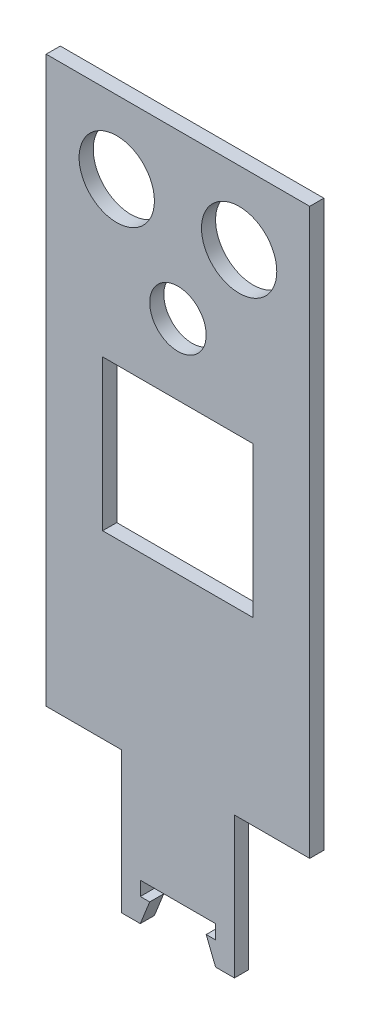
from build123d import *

# Parameters (mm, degrees)
MODEL_R                 = 6
MODEL_R_2               = 8
MODEL_W                 = 32
MODEL_H                 = 32
SALIENTE_EXTRUIR1_DEPTH = 3


with BuildPart() as part:
    # Model → Saliente-Extruir1 (new body)
    with BuildSketch(Plane.XY):
        Polygon((18.582508913, 92.133016607), (18.582508913, -27.866983393), (2.582508913, -27.866983393), (2.582508913, -57.866983393), (-1.417491087, -57.866983393), (-3.417491087, -52.866983393), (-1.417491087, -52.866983393), (-1.417491087, -49.866983393), (-17.417491087, -49.866983393), (-17.417491087, -52.866983393), (-15.417491087, -52.866983393), (-17.417491087, -57.866983393), (-21.417491087, -57.866983393), (-21.417491087, -27.866983393), (-37.417491087, -27.866983393), (-37.417491087, 92.133016607), align=None)
        with Locations((-9.417491087, 57.433016607)):
            Circle(MODEL_R, mode=Mode.SUBTRACT)
        with Locations((-22.417491087, 76.633016607)):
            Circle(MODEL_R_2, mode=Mode.SUBTRACT)
        with Locations((3.582508913, 76.633016607)):
            Circle(MODEL_R_2, mode=Mode.SUBTRACT)
        with Locations((-9.417491087, 26.433016607)):
            Rectangle(MODEL_W, MODEL_H, mode=Mode.SUBTRACT)
    extrude(amount=SALIENTE_EXTRUIR1_DEPTH)


solid = part.part
